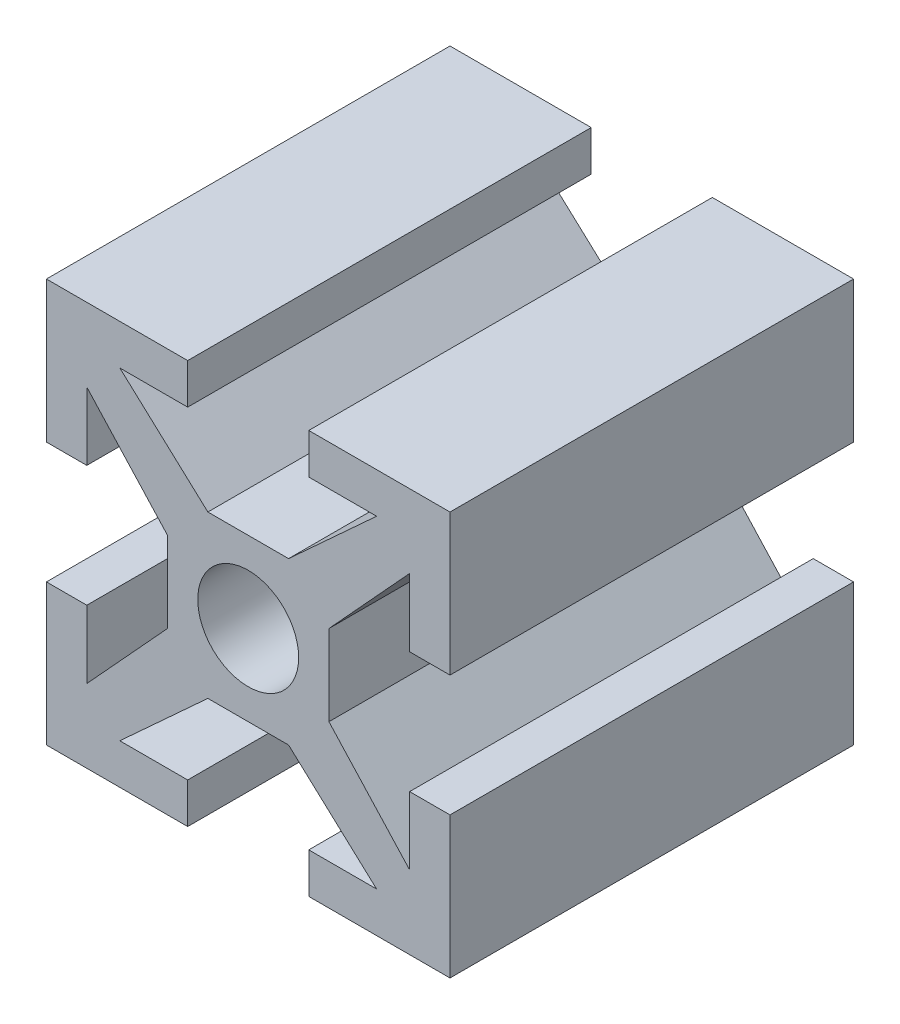
from build123d import *

# Parameters (mm, degrees)
SKETCH1_R           = 1.25
BOSS_EXTRUDE2_DEPTH = 10


with BuildPart() as part:
    # Sketch1 → Boss-Extrude2 (new body)
    with BuildSketch(Plane.XY):
        Polygon((-4, 3.181649314), (-2, 1), (-2, 0), (-2, -1), (-4, -3.181649314), (-4, -1.5), (-5, -1.5), (-5, -5), (-1.5, -5), (-1.5, -4), (-3.181649314, -4), (-1, -2), (0, -2), (1, -2), (3.181649314, -4), (1.5, -4), (1.5, -5), (5, -5), (5, -1.5), (4, -1.5), (4, -3.181649314), (2, -1), (2, 0), (2, 1), (4, 3.181649314), (4, 1.5), (5, 1.5), (5, 5), (1.5, 5), (1.5, 4), (3.181649314, 4), (1, 2), (0, 2), (-1, 2), (-3.181649314, 4), (-1.5, 4), (-1.5, 5), (-5, 5), (-5, 1.5), (-4, 1.5), align=None)
        Circle(SKETCH1_R, mode=Mode.SUBTRACT)
    extrude(amount=BOSS_EXTRUDE2_DEPTH)


solid = part.part
